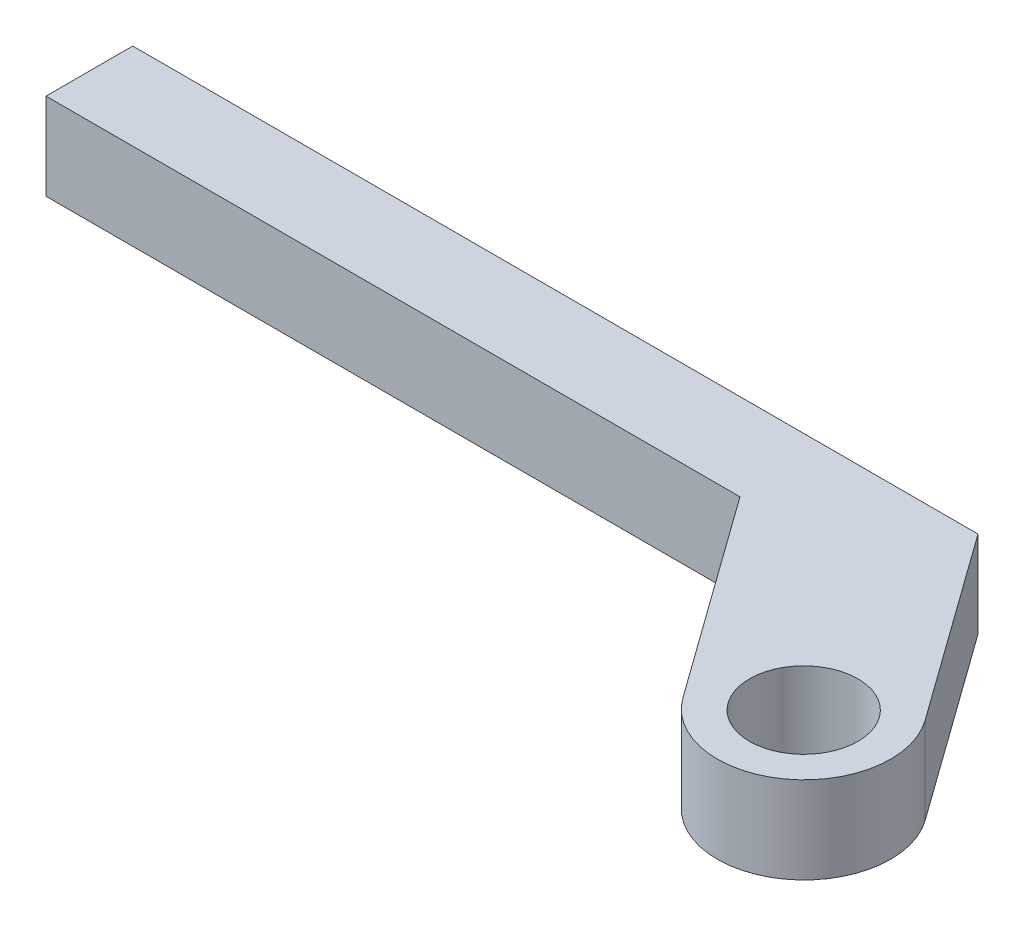
from build123d import *

# Parameters (mm, degrees)
BOSS_EXTRUDE1_DEPTH         = 6.35
F_3_8_16_TAPPED_HOLE1_D     = 7.9375
F_3_8_16_TAPPED_HOLE1_DEPTH = 6.35
F_3_8_16_TAPPED_HOLE1_TIP   = 2.384665582


with BuildPart() as part:
    # Sketch2 → Boss-Extrude1 (new body)
    with BuildSketch(Plane(origin=(0, 0, 0), x_dir=(1, 0, 0), z_dir=(0, 1, 0))):
        with BuildLine():
            Line((-10.638933845, -0.317978242), (0.0062465, -15.135448057))
            ThreePointArc((0.0062465, -15.135448057), (8.868318086, -16.587580012), (10.320450041, -7.725508427))
            Line((10.320450041, -7.725508427), (0.436752504, 6.032021758))
            Line((0.436752504, 6.032021758), (-10.638933845, 6.032021758))
            Line((-10.638933845, 6.032021758), (-61.438933845, 6.032021758))
            Line((-61.438933845, 6.032021758), (-61.438933845, -0.317978242))
            Line((-61.438933845, -0.317978242), (-10.638933845, -0.317978242))
        make_face()
    extrude(amount=BOSS_EXTRUDE1_DEPTH)

    # 3/8-16 Tapped Hole1
    with Locations(Plane(origin=(0, 6.35, 0), x_dir=(1, 0, 0), z_dir=(0, 1, 0))):
        with Locations((5.218739795, -11.507580012)):
            Hole(F_3_8_16_TAPPED_HOLE1_D / 2, depth=F_3_8_16_TAPPED_HOLE1_DEPTH)
            with Locations((0, 0, -(F_3_8_16_TAPPED_HOLE1_DEPTH + F_3_8_16_TAPPED_HOLE1_TIP / 2))):  # 118° drill point
                Cone(0, F_3_8_16_TAPPED_HOLE1_D / 2, F_3_8_16_TAPPED_HOLE1_TIP, mode=Mode.SUBTRACT)


solid = part.part
